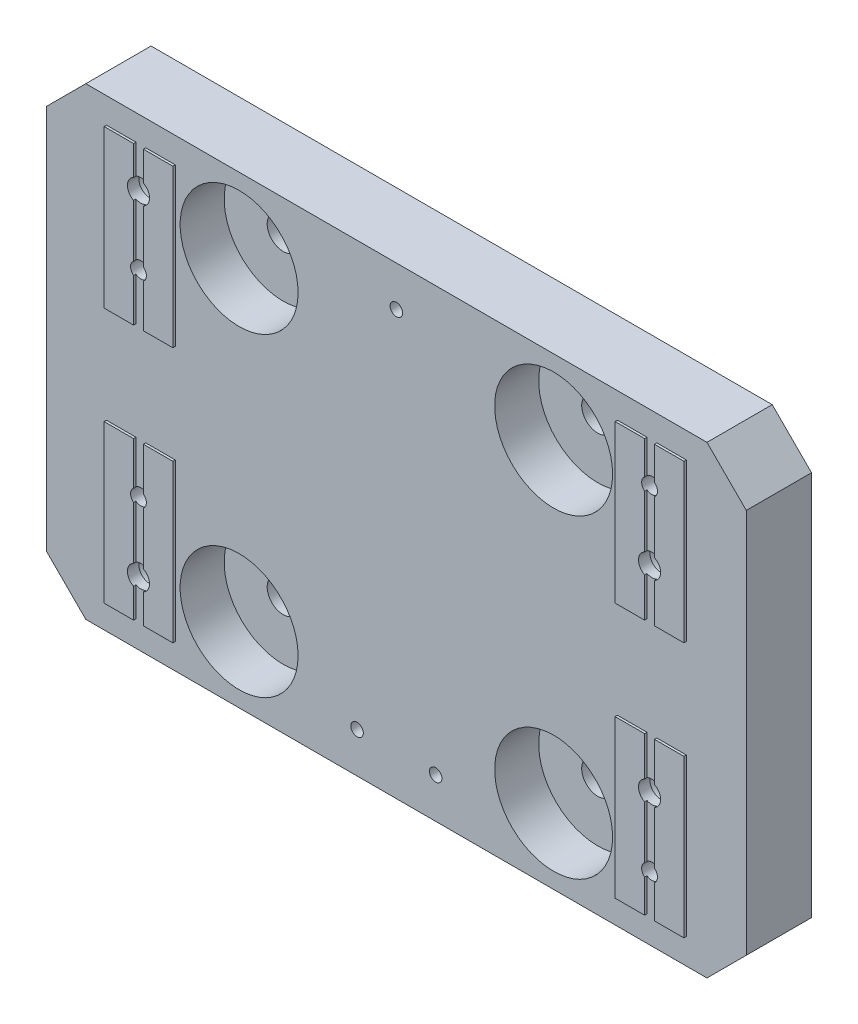
from build123d import *

# Parameters (mm, degrees)
SKETCH3_W                                        = 226.06
SKETCH3_H                                        = 149.86
EXTRUDE2_DEPTH                                   = 21.844
SKETCH4_W                                        = 226.06
SKETCH4_H                                        = 149.86
SKETCH4_W_2                                      = 22.225
SKETCH4_H_2                                      = 50.8
EXTRUDE4_DEPTH                                   = 0.762
F_1_4_20_TAPPED_HOLE1_D                          = 5.1054
CBORE_FOR_3_8_SOCKET_HEAD_CAP_SCREW1_D           = 10.31748
CBORE_FOR_3_8_SOCKET_HEAD_CAP_SCREW1_CBORE_D     = 38.1
CBORE_FOR_3_8_SOCKET_HEAD_CAP_SCREW1_CBORE_DEPTH = 14.224
SKETCH17_W                                       = 3.175
SKETCH17_H                                       = 133.35
CUT_EXTRUDE1_DEPTH                               = 0.762
CBORE_FOR_1_4_SOCKET_HEAD_CAP_SCREW1_AT_COUNT    = 2
CBORE_FOR_1_4_SOCKET_HEAD_CAP_SCREW1_AT_PITCH    = 63.5
CBORE_FOR_1_4_SOCKET_HEAD_CAP_SCREW1_2_COUNT     = 2
CBORE_FOR_1_4_SOCKET_HEAD_CAP_SCREW1_2_PITCH     = 186.028991356
CBORE_FOR_1_4_SOCKET_HEAD_CAP_SCREW1_3_COUNT     = 2
CBORE_FOR_1_4_SOCKET_HEAD_CAP_SCREW1_3_PITCH     = 166.589197204
F_10_32_TAPPED_HOLE1_D                           = 4.0386
CHAMFER1_SIZE                                    = 12.7


with BuildPart() as part:
    # Sketch3 → Extrude2 (new body)
    with BuildSketch(Plane.XY):
        with Locations((113.03, -74.93)):
            Rectangle(SKETCH3_W, SKETCH3_H)
    extrude(amount=EXTRUDE2_DEPTH)

    # Sketch4 → Extrude4 (cut)
    with BuildSketch(Plane.XY.offset(21.844)):
        with Locations((113.03, -74.93)):
            Rectangle(SKETCH4_W, SKETCH4_H)
        with Locations((30.4927, -116.205)):
            Rectangle(SKETCH4_W_2, SKETCH4_H_2, mode=Mode.SUBTRACT)
        with Locations((30.4927, -33.655)):
            Rectangle(SKETCH4_W_2, SKETCH4_H_2, mode=Mode.SUBTRACT)
        with Locations((195.5673, -116.205)):
            Rectangle(SKETCH4_W_2, SKETCH4_H_2, mode=Mode.SUBTRACT)
        with Locations((195.5673, -33.655)):
            Rectangle(SKETCH4_W_2, SKETCH4_H_2, mode=Mode.SUBTRACT)
    extrude(amount=-EXTRUDE4_DEPTH, mode=Mode.SUBTRACT)

    # 1/4-20 Tapped Hole1 (through all)
    with Locations(Plane(origin=(0, 0, 0), x_dir=(-1, 0, 0), z_dir=(0, 0, -1))):
        with Locations((-195.58, -20.955), (-195.58, -128.905), (-30.48, -43.18), (-30.48, -106.68)):
            Hole(F_1_4_20_TAPPED_HOLE1_D / 2)

    # CBORE for 3/8 Socket Head Cap Screw1 (through all)
    with Locations(Plane.XY.offset(21.082)):
        with Locations((62.23, -125.73), (163.83, -24.13), (62.23, -24.13), (163.83, -125.73)):
            CounterBoreHole(CBORE_FOR_3_8_SOCKET_HEAD_CAP_SCREW1_D / 2, CBORE_FOR_3_8_SOCKET_HEAD_CAP_SCREW1_CBORE_D / 2, CBORE_FOR_3_8_SOCKET_HEAD_CAP_SCREW1_CBORE_DEPTH)

    # Sketch17 → Cut-Extrude1 (cut)
    with BuildSketch(Plane.XY.offset(21.844)):
        with Locations((195.58, -74.93)):
            Rectangle(SKETCH17_W, SKETCH17_H)
        with Locations((30.48, -74.93)):
            Rectangle(SKETCH17_W, SKETCH17_H)
    extrude(amount=-CUT_EXTRUDE1_DEPTH, mode=Mode.SUBTRACT)

    # Sketch19 → CBORE for 1/4 Socket Head Cap Screw1 (revolve, cut)
    with BuildSketch(Plane(origin=(195.58, -106.68, 0), x_dir=(0, 1, 0), z_dir=(1, 0, 0))):
        Polygon((0, 0), (0, 21.844), (3.57124, 21.844), (3.57124, 18.161), (5.55625, 18.161), (5.55625, 0.635), (6.19125, 0), align=None)
    cbore_for_1_4_socket_head_cap_screw1 = revolve(axis=Axis((195.58, -106.68, -6.35), (0, 0, 1)), mode=Mode.SUBTRACT)

    # CBORE for 1/4 Socket Head Cap Screw1 at: CBORE for 1/4 Socket Head Cap Screw1 ×2
    with Locations(*[(0, i * CBORE_FOR_1_4_SOCKET_HEAD_CAP_SCREW1_AT_PITCH, 0) for i in range(1, CBORE_FOR_1_4_SOCKET_HEAD_CAP_SCREW1_AT_COUNT)]):
        add(cbore_for_1_4_socket_head_cap_screw1, mode=Mode.SUBTRACT)

    # CBORE for 1_4 Socket Head Cap Screw1 2: CBORE for 1/4 Socket Head Cap Screw1 ×2
    with Locations(*[Vector(-0.887496077, 0.460815271, 0) * (i * CBORE_FOR_1_4_SOCKET_HEAD_CAP_SCREW1_2_PITCH) for i in range(1, CBORE_FOR_1_4_SOCKET_HEAD_CAP_SCREW1_2_COUNT)]):
        add(cbore_for_1_4_socket_head_cap_screw1, mode=Mode.SUBTRACT)

    # CBORE for 1_4 Socket Head Cap Screw1 3: CBORE for 1/4 Socket Head Cap Screw1 ×2
    with Locations(*[Vector(-0.991060662, -0.133412012, 0) * (i * CBORE_FOR_1_4_SOCKET_HEAD_CAP_SCREW1_3_PITCH) for i in range(1, CBORE_FOR_1_4_SOCKET_HEAD_CAP_SCREW1_3_COUNT)]):
        add(cbore_for_1_4_socket_head_cap_screw1, mode=Mode.SUBTRACT)

    # #10-32 Tapped Hole1 (through all)
    with Locations(Plane(origin=(0, 0, 0), x_dir=(-1, 0, 0), z_dir=(0, 0, -1))):
        with Locations((-100.33, -136.8552), (-125.73, -136.8552), (-113.03, -13.0048)):
            Hole(F_10_32_TAPPED_HOLE1_D / 2)

    # Chamfer1
    chamfer1_edges = [part.edges().sort_by_distance(p)[0] for p in [
        (0, 0, 10.541),
        (226.06, 0, 10.541),
        (226.06, -149.86, 10.541),
        (0, -149.86, 10.541),
    ]]
    chamfer(chamfer1_edges, length=CHAMFER1_SIZE)


solid = part.part
